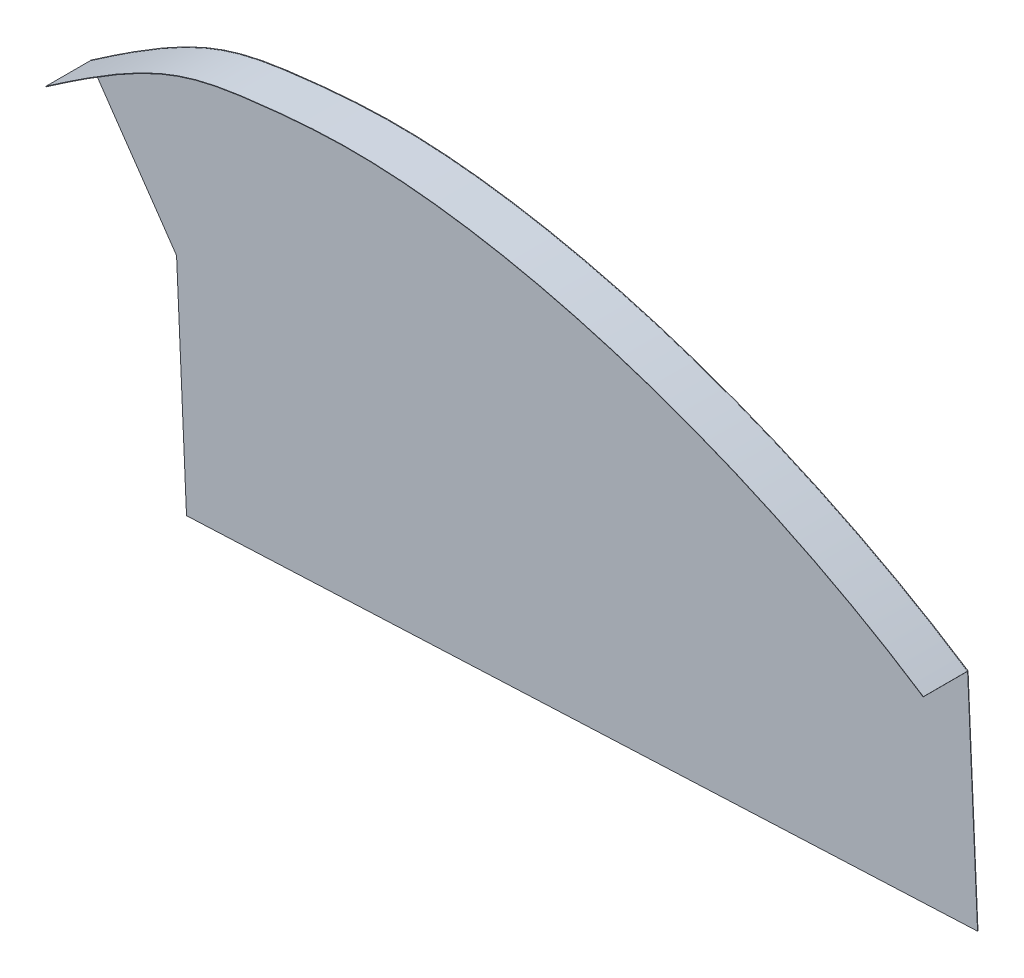
from build123d import *

# Parameters (mm, degrees)
BOSS_EXTRUDE1_DEPTH = 0.1
BOSS_EXTRUDE2_DEPTH = 10


with BuildPart() as part:
    # Sketch1 → Boss-Extrude1 (new body)
    with BuildSketch(Plane.XY):
        with BuildLine():
            Line((-1544.649956659, 573.44143308), (-1542.397344254, 523.492201481))
            Line((-1542.397344254, 523.492201481), (-1721.722963635, 515.404967666))
            Line((-1721.722963635, 515.404967666), (-1723.97557604, 565.354199265))
            Line((-1723.97557604, 565.354199265), (-1743.607960183, 593.830470178))
            add(Edge.make_bspline(
                [(-1743.607960183, 593.830470178), (-1719.507904213, 610.537812828), (-1709.389541143, 613.399774739), (-1646.280289738, 619.241808081), (-1585.716648888, 600.423930323), (-1544.649956659, 573.44143308)],
                knots=[0, 0, 0, 0, 0.320554642, 0.420554642, 1, 1, 1, 1], degree=3))
        make_face()
    extrude(amount=BOSS_EXTRUDE1_DEPTH)

    # Sketch2 → Boss-Extrude2 (add)
    with BuildSketch(Plane.XY.offset(0.1)):
        with BuildLine():
            Line((-1544.677412579, 573.399645851), (-1544.732324417, 573.316071394))
            add(Edge.make_bspline(
                [(-1544.732324417, 573.316071394), (-1546.951948835, 574.774455463), (-1551.43127801, 577.613556033), (-1560.629429442, 583.045346231), (-1572.470935952, 589.326889692), (-1587.069867375, 596.019330748), (-1606.812651261, 603.755089396), (-1626.620904389, 609.625271881), (-1645.785452529, 613.461587482), (-1659.664022733, 615.275078476), (-1672.855430865, 616.000525973), (-1683.17584634, 615.607177853), (-1690.719151522, 614.940047919), (-1697.619410573, 614.184343593), (-1704.94143994, 613.175751133), (-1711.537062872, 611.520585877), (-1716.950731756, 609.496349748), (-1721.226339774, 607.54713974), (-1725.861820037, 605.087085053), (-1730.144377714, 602.544994912), (-1733.894814235, 600.175895508), (-1736.886084267, 598.222624564), (-1739.548362017, 596.435520579), (-1741.775682708, 594.914415574), (-1742.945821332, 594.106977842), (-1743.522500251, 593.707195687)],
                knots=[0, 0, 0, 0, 0.03125, 0.0625, 0.125, 0.1875, 0.25, 0.375, 0.4375, 0.5, 0.5625, 0.625, 0.65625, 0.6875, 0.75, 0.8125, 0.84375, 0.875, 0.90625, 0.9375, 0.953125, 0.96875, 0.984375, 0.9921875, 1, 1, 1, 1], degree=3))
            Line((-1743.522500251, 593.707195687), (-1743.579473539, 593.789378681))
            add(Edge.make_bspline(
                [(-1544.677412579, 573.399645851), (-1580.106306882, 596.677879158), (-1623.417276611, 611.817205851), (-1664.055554326, 615.615316249), (-1668.458587485, 615.853546332), (-1674.850456886, 615.924640206), (-1676.947072346, 615.898899542), (-1681.053950245, 615.760083504), (-1685.070934683, 615.538033819), (-1688.841535286, 615.206941309), (-1692.455660822, 614.85004283), (-1694.182553399, 614.660043123), (-1699.092177305, 614.084892783), (-1702.026740338, 613.678931579), (-1710.391454065, 612.076086015), (-1715.382812403, 610.494610736), (-1727.278520434, 604.6086441), (-1734.182625539, 600.30373531), (-1743.579473539, 593.789378681)],
                knots=[0, 0, 0, 0, 0.5, 0.5, 0.5625, 0.5625, 0.59375, 0.59375, 0.625, 0.65625, 0.65625, 0.6875, 0.6875, 0.75, 0.75, 0.875, 0.875, 1, 1, 1, 1], degree=3))
        make_face()
    extrude(amount=BOSS_EXTRUDE2_DEPTH)


solid = part.part
